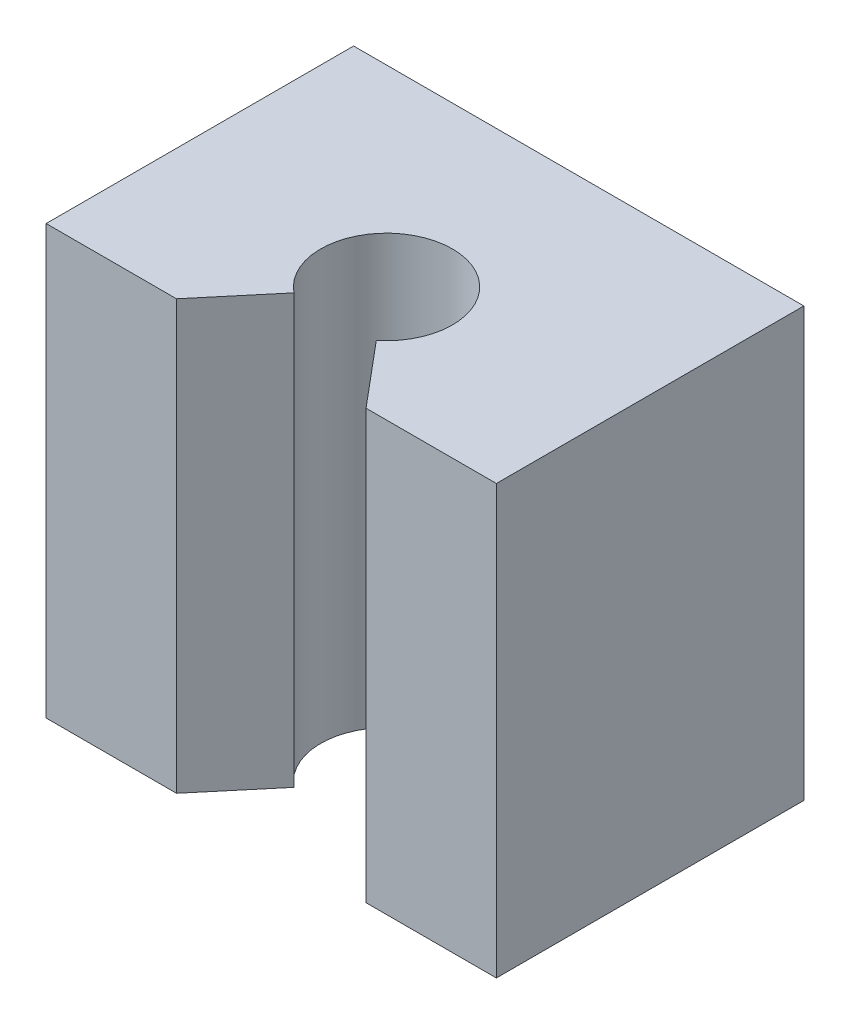
from build123d import *

# Parameters (mm, degrees)
SKETCH1_W               = 41
SKETCH1_H               = 28
SKETCH1_R               = 6
BOSS_EXTRUDE1_DEPTH     = 39
CUT_EXTRUDE1_DEPTH      = 1
CUT_EXTRUDE1_DEPTH_BACK = 40
SKETCH3_R               = 2.5
CUT_EXTRUDE2_DEPTH      = 10


with BuildPart() as part:
    # Sketch1 → Boss-Extrude1 (new body)
    with BuildSketch(Plane(origin=(0, 0, 0), x_dir=(1, 0, 0), z_dir=(0, 1, 0))):
        with Locations((0, 3.5)):
            Rectangle(SKETCH1_W, SKETCH1_H)
        Circle(SKETCH1_R, mode=Mode.SUBTRACT)
    extrude(amount=BOSS_EXTRUDE1_DEPTH)

    # Sketch2 → Cut-Extrude1 (cut, two sides)
    with BuildSketch(Plane(origin=(0, 39, 0), x_dir=(1, 0, 0), z_dir=(0, 1, 0))) as cut_extrude1_sk:
        with BuildLine():
            ThreePointArc((3.75, -4.683748499), (0, -6), (-3.75, -4.683748499))
            Line((-3.75, -4.683748499), (-8.630414489, -10.5))
            Line((-8.630414489, -10.5), (8.630414489, -10.5))
            Line((8.630414489, -10.5), (3.75, -4.683748499))
        make_face()
    extrude(amount=CUT_EXTRUDE1_DEPTH, mode=Mode.SUBTRACT)
    extrude(cut_extrude1_sk.sketch, amount=-CUT_EXTRUDE1_DEPTH_BACK, mode=Mode.SUBTRACT)

    # Sketch3 → Cut-Extrude2 (cut)
    with BuildSketch(Plane(origin=(0, 0, -17.5), x_dir=(-1, 0, 0), z_dir=(0, 0, -1))):
        with Locations((14, 32.5)):
            Circle(SKETCH3_R)
        with Locations((-14, 6.5)):
            Circle(SKETCH3_R)
        with Locations((-14, 32.5)):
            Circle(SKETCH3_R)
        with Locations((14, 6.5)):
            Circle(SKETCH3_R)
    extrude(amount=-CUT_EXTRUDE2_DEPTH, mode=Mode.SUBTRACT)


solid = part.part
